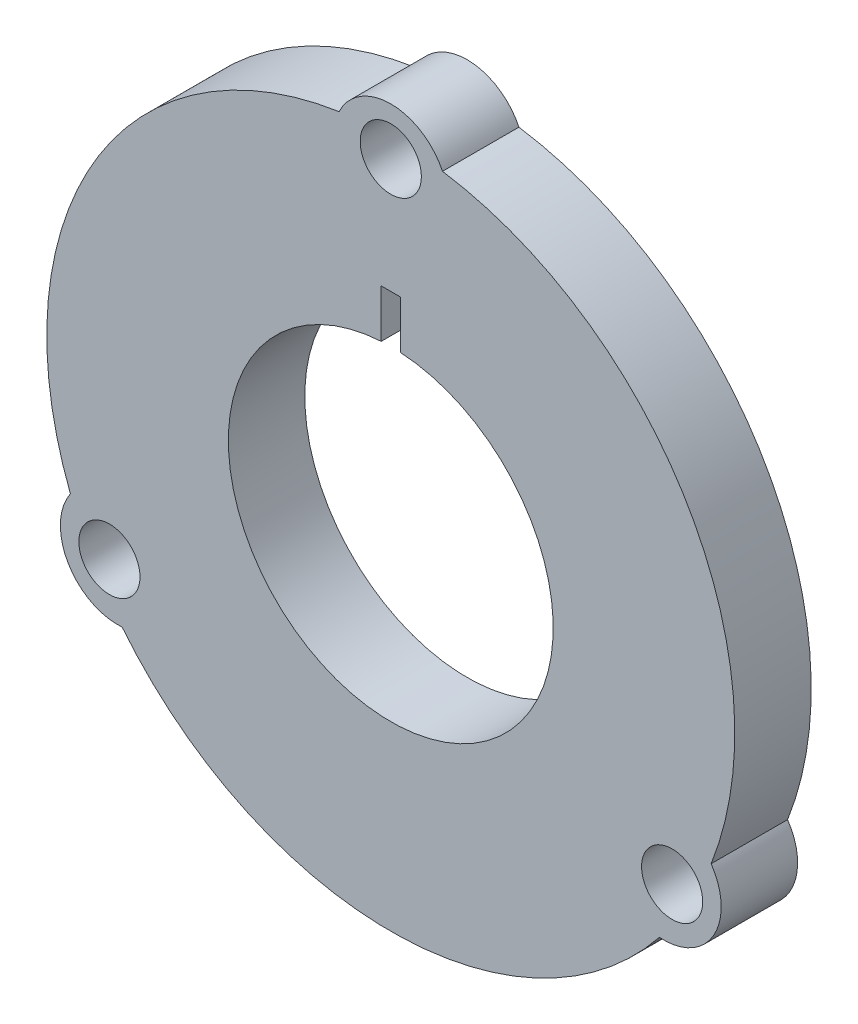
from build123d import *

# Parameters (mm, degrees)
SKETCH_1_R               = 8.5
EXTRUDE_1_DEPTH          = 4
SKETCH_2_R               = 1.6
CUT_EXTRUDE_1_DEPTH      = 10
CUT_EXTRUDE_3_DEPTH      = 1
CUT_EXTRUDE_3_DEPTH_BACK = 4


with BuildPart() as part:
    # 草图1 → 凸台-拉伸1 (new body)
    with BuildSketch(Plane.XY):
        with BuildLine():
            ThreePointArc((-14.058374697, -11.241089844), (0, -18), (14.058374697, -11.241089844))
            ThreePointArc((14.058374697, -11.241089844), (16.887495374, -9.75), (16.76425672, -6.554364701))
            ThreePointArc((16.76425672, -6.554364701), (15.588457268, 9), (2.705882023, 17.795454545))
            ThreePointArc((2.705882023, 17.795454545), (0, 19.5), (-2.705882023, 17.795454545))
            ThreePointArc((-2.705882023, 17.795454545), (-15.588457268, 9), (-16.76425672, -6.554364701))
            ThreePointArc((-16.76425672, -6.554364701), (-16.887495374, -9.75), (-14.058374697, -11.241089844))
        make_face()
        Circle(SKETCH_1_R, mode=Mode.SUBTRACT)
    extrude(amount=EXTRUDE_1_DEPTH)

    # 草图2 → 切除-拉伸1 (cut)
    with BuildSketch(Plane.XY.offset(4)):
        with Locations((0, 17)):
            Circle(SKETCH_2_R)
        with Locations((14.722431864, -8.5)):
            Circle(SKETCH_2_R)
        with Locations((-14.722431864, -8.5)):
            Circle(SKETCH_2_R)
    extrude(amount=-CUT_EXTRUDE_1_DEPTH, mode=Mode.SUBTRACT)

    # 草图3 → 切除-拉伸3 (cut, two sides)
    with BuildSketch(Plane(origin=(0, 0, 0), x_dir=(-1, 0, 0), z_dir=(0, 0, -1))) as cut_extrude_3_sk:
        with BuildLine():
            ThreePointArc((-0.5, 8.485281374), (0, 8.5), (0.5, 8.485281374))
            Line((0.5, 8.485281374), (0.5, 11))
            Line((0.5, 11), (-0.5, 11))
            Line((-0.5, 11), (-0.5, 8.485281374))
        make_face()
    extrude(amount=CUT_EXTRUDE_3_DEPTH, mode=Mode.SUBTRACT)
    extrude(cut_extrude_3_sk.sketch, amount=-CUT_EXTRUDE_3_DEPTH_BACK, mode=Mode.SUBTRACT)


solid = part.part
